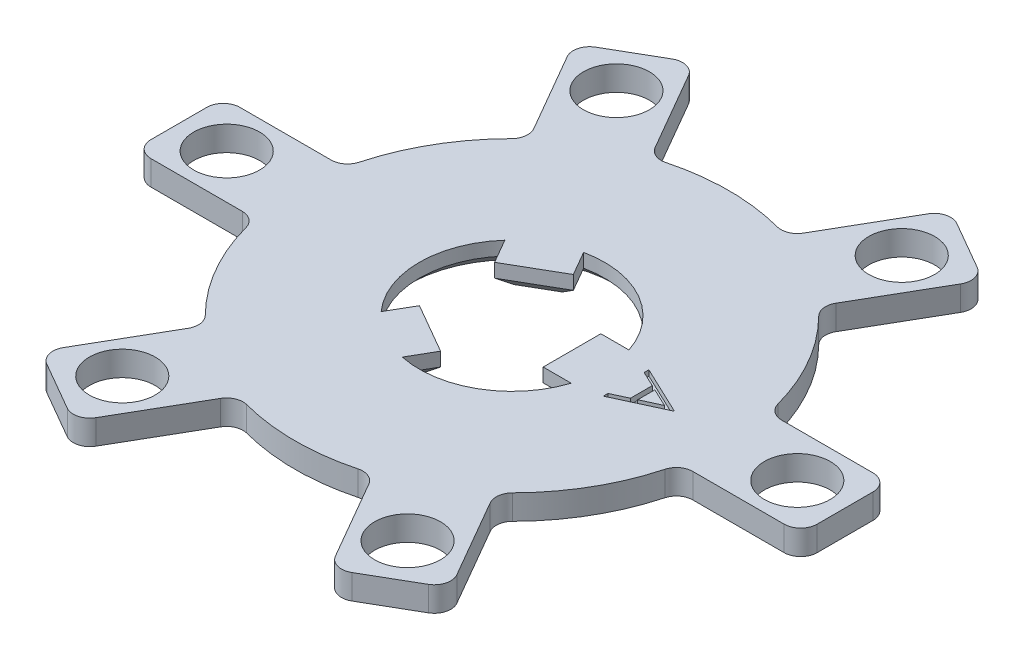
from build123d import *

# Parameters (mm, degrees)
SKETCH1_R           = 2.4
BOSS_EXTRUDE1_DEPTH = 1.8
FILLET11_R          = 1.2
CUT_EXTRUDE3_DEPTH  = 0.4
CUT_EXTRUDE4_DEPTH  = 2.5
CHAMFER1_SIZE       = 0.8
SCALE1_SCALE        = 1.15


with BuildPart() as part:
    # Sketch1 → Boss-Extrude1 (new body)
    with BuildSketch(Plane(origin=(0, 0, 0), x_dir=(1, 0, 0), z_dir=(0, 1, 0))):
        with BuildLine():
            Line((4.929751496, -15.011247456), (9.329383596, -22.631633787))
            Line((9.329383596, -22.631633787), (14.934877991, -19.395300089))
            Line((14.934877991, -19.395300089), (10.535245891, -11.774913758))
            ThreePointArc((10.535245891, -11.774913758), (13.68320138, -7.9), (15.464997388, -3.236333698))
            Line((15.464997388, -3.236333698), (24.264261587, -3.236333698))
            Line((24.264261587, -3.236333698), (24.264261587, 3.236333698))
            Line((24.264261587, 3.236333698), (15.464997388, 3.236333698))
            ThreePointArc((15.464997388, 3.236333698), (13.68320138, 7.9), (10.535245891, 11.774913758))
            Line((10.535245891, 11.774913758), (14.934877991, 19.395300089))
            Line((14.934877991, 19.395300089), (9.329383596, 22.631633787))
            Line((9.329383596, 22.631633787), (4.929751496, 15.011247456))
            ThreePointArc((4.929751496, 15.011247456), (0, 15.8), (-4.929751496, 15.011247456))
            Line((-4.929751496, 15.011247456), (-9.329383596, 22.631633787))
            Line((-9.329383596, 22.631633787), (-14.934877991, 19.395300089))
            Line((-14.934877991, 19.395300089), (-10.535245891, 11.774913758))
            ThreePointArc((-10.535245891, 11.774913758), (-13.68320138, 7.9), (-15.464997388, 3.236333698))
            Line((-15.464997388, 3.236333698), (-24.264261587, 3.236333698))
            Line((-24.264261587, 3.236333698), (-24.264261587, -3.236333698))
            Line((-24.264261587, -3.236333698), (-15.464997388, -3.236333698))
            ThreePointArc((-15.464997388, -3.236333698), (-13.68320138, -7.9), (-10.535245891, -11.774913758))
            Line((-10.535245891, -11.774913758), (-14.934877991, -19.395300089))
            Line((-14.934877991, -19.395300089), (-9.329383596, -22.631633787))
            Line((-9.329383596, -22.631633787), (-4.929751496, -15.011247456))
            ThreePointArc((-4.929751496, -15.011247456), (0, -15.8), (4.929751496, -15.011247456))
        make_face()
        with Locations((20.784609691, 0)):
            Circle(SKETCH1_R, mode=Mode.SUBTRACT)
        with Locations((10.392304845, -18)):
            Circle(SKETCH1_R, mode=Mode.SUBTRACT)
        with Locations((-10.392304845, -18)):
            Circle(SKETCH1_R, mode=Mode.SUBTRACT)
        with Locations((-20.784609691, 0)):
            Circle(SKETCH1_R, mode=Mode.SUBTRACT)
        with Locations((-10.392304845, 18)):
            Circle(SKETCH1_R, mode=Mode.SUBTRACT)
        with Locations((10.392304845, 18)):
            Circle(SKETCH1_R, mode=Mode.SUBTRACT)
    extrude(amount=BOSS_EXTRUDE1_DEPTH)

    # Fillet11
    fillet11_edges = [part.edges().sort_by_distance(p)[0] for p in [
        (24.264261587, 0.9, 3.236333698),
        (15.464997388, 0.9, 3.236333698),
        (10.535245891, 0.9, 11.774913758),
        (14.934877991, 0.9, 19.395300089),
        (9.329383596, 0.9, 22.631633787),
        (4.929751496, 0.9, 15.011247456),
        (-4.929751496, 0.9, 15.011247456),
        (-9.329383596, 0.9, 22.631633787),
        (-14.934877991, 0.9, 19.395300089),
        (-10.535245891, 0.9, 11.774913758),
        (-15.464997388, 0.9, 3.236333698),
        (-24.264261587, 0.9, 3.236333698),
        (-24.264261587, 0.9, -3.236333698),
        (-15.464997388, 0.9, -3.236333698),
        (-10.535245891, 0.9, -11.774913758),
        (-14.934877991, 0.9, -19.395300089),
        (-9.329383596, 0.9, -22.631633787),
        (-4.929751496, 0.9, -15.011247456),
        (4.929751496, 0.9, -15.011247456),
        (9.329383596, 0.9, -22.631633787),
        (14.934877991, 0.9, -19.395300089),
        (10.535245891, 0.9, -11.774913758),
        (15.464997388, 0.9, -3.236333698),
        (24.264261587, 0.9, -3.236333698),
    ]]
    fillet(fillet11_edges, radius=FILLET11_R)

    # Sketch10 → Cut-Extrude3 (cut)
    with BuildSketch(Plane(origin=(0, 1.8, 0), x_dir=(1, 0, 0), z_dir=(0, 1, 0))):
        Polygon((11.897175645, -0.131244585), (8.397175645, -1.7466292), (8.397175645, -1.405182886), (9.518970517, -0.887755001), (9.518970517, 0.698883621), (8.397175645, 1.231035063), (8.397175645, 1.573883621), (11.897175645, -0.08637279), align=None)
        Polygon((11.214984138, -0.105303078), (9.877944876, 0.528511024), (9.877944876, -0.722290258), align=None, mode=Mode.SUBTRACT)
    extrude(amount=-CUT_EXTRUDE3_DEPTH, mode=Mode.SUBTRACT)

    # Sketch11 → Cut-Extrude4 (cut, symmetric)
    with BuildSketch(Plane(origin=(0, 0, 0), x_dir=(1, 0, 0), z_dir=(0, 1, 0))):
        with BuildLine():
            Line((-0.367543966, -4.836604823), (-4.004850662, -2.736604823))
            Line((-4.004850662, -2.736604823), (-5.026164065, -4.505571528))
            ThreePointArc((-5.026164065, -4.505571528), (-6.75, 0), (-5.026164065, 4.505571528))
            Line((-5.026164065, 4.505571528), (-4.004850662, 2.736604823))
            Line((-4.004850662, 2.736604823), (-0.367543966, 4.836604823))
            Line((-0.367543966, 4.836604823), (-1.388857369, 6.605571528))
            ThreePointArc((-1.388857369, 6.605571528), (3.375, 5.845671476), (6.415021434, 2.1))
            Line((6.415021434, 2.1), (4.372394628, 2.1))
            Line((4.372394628, 2.1), (4.372394628, -2.1))
            Line((4.372394628, -2.1), (6.415021434, -2.1))
            ThreePointArc((6.415021434, -2.1), (3.375, -5.845671476), (-1.388857369, -6.605571528))
            Line((-1.388857369, -6.605571528), (-0.367543966, -4.836604823))
        make_face()
    extrude(amount=CUT_EXTRUDE4_DEPTH, both=True, mode=Mode.SUBTRACT)

    # Chamfer1
    chamfer1_edges = [part.edges().sort_by_distance(p)[0] for p in [
        (5.393708031, 0, -2.1),
        (4.372394628, 0, 0),
        (5.393708031, 0, 2.1),
        (3.375, 0, 5.845671476),
        (-0.878200668, 0, 5.721088175),
        (-2.186197314, 0, 3.786604823),
        (-4.515507363, 0, 3.621088175),
        (-6.75, 0, 0),
        (-4.515507363, 0, -3.621088175),
        (-2.186197314, 0, -3.786604823),
        (-0.878200668, 0, -5.721088175),
        (3.375, 0, -5.845671476),
    ]]
    chamfer(chamfer1_edges, length=CHAMFER1_SIZE)


with BuildPart() as part_1:
    # Scale1: scaled about (-0.006722783, 0.906799408, -6.4443e-05)
    add(part.part.scale(SCALE1_SCALE).moved(Location((0.001008417, -0.136019911, 9.666e-06))))


solid = part_1.part
